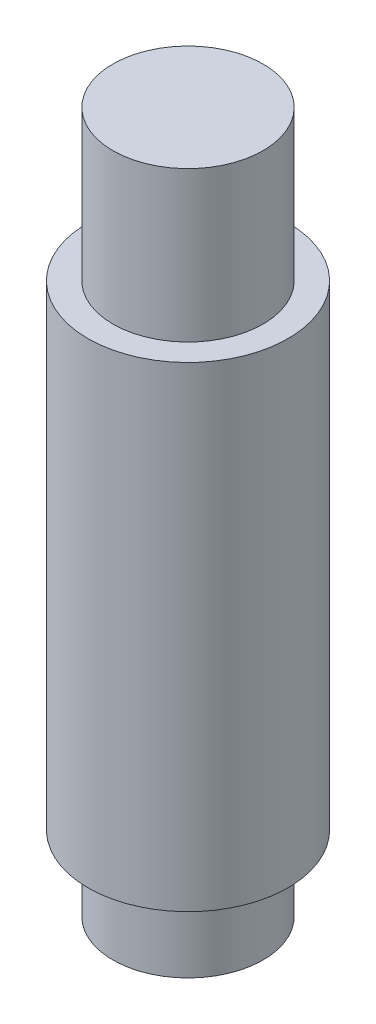
from build123d import *

# Parameters (mm, degrees)
SKETCH1_R           = 20
BOSS_EXTRUDE1_DEPTH = 40
SKETCH2_R           = 15
BOSS_EXTRUDE2_DEPTH = 30
SKETCH3_R           = 15
BOSS_EXTRUDE3_DEPTH = 30
SKETCH4_R           = 20
BOSS_EXTRUDE4_DEPTH = 15


with BuildPart() as part:
    # Sketch1 → Boss-Extrude1 (new body, symmetric)
    with BuildSketch(Plane(origin=(0, 0, 0), x_dir=(1, 0, 0), z_dir=(0, 1, 0))):
        Circle(SKETCH1_R)
    extrude(amount=BOSS_EXTRUDE1_DEPTH, both=True)

    # Sketch2 → Boss-Extrude2 (add)
    with BuildSketch(Plane(origin=(0, 40, 0), x_dir=(1, 0, 0), z_dir=(0, 1, 0))):
        Circle(SKETCH2_R)
    extrude(amount=BOSS_EXTRUDE2_DEPTH)

    # Sketch3 → Boss-Extrude3 (add)
    with BuildSketch(Plane.XZ.offset(40)):
        Circle(SKETCH3_R)
    extrude(amount=BOSS_EXTRUDE3_DEPTH)

    # Sketch4 → Boss-Extrude4 (add)
    with BuildSketch(Plane.XZ.offset(40)):
        Circle(SKETCH4_R)
    extrude(amount=BOSS_EXTRUDE4_DEPTH)


solid = part.part
